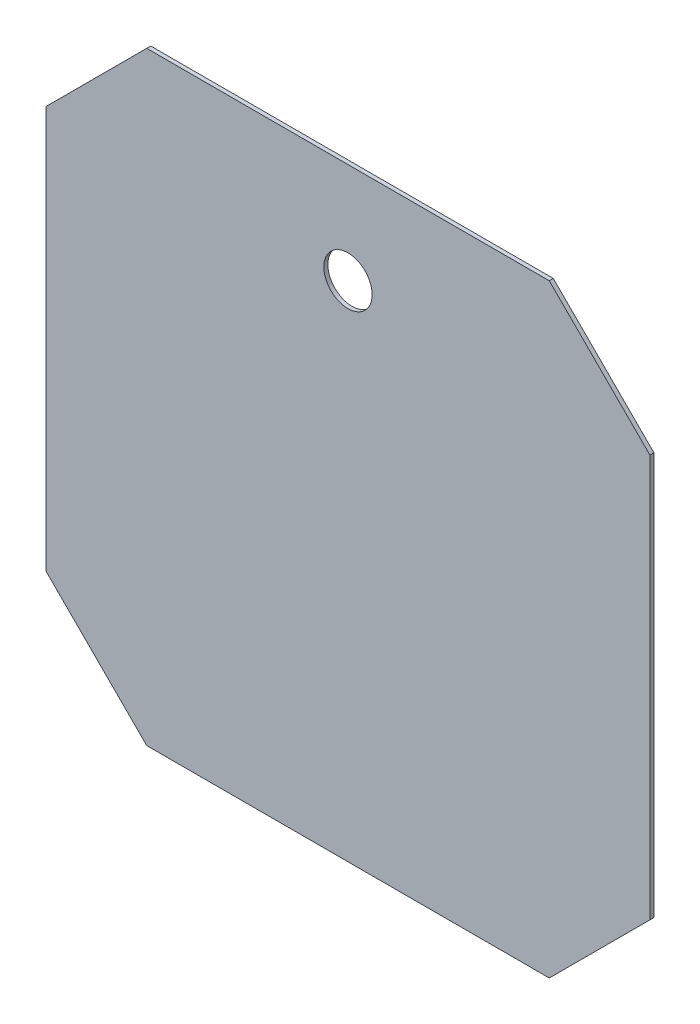
from build123d import *

# Parameters (mm, degrees)
SKETCH1_R           = 6
BOSS_EXTRUDE1_DEPTH = 1


with BuildPart() as part:
    # Sketch1 → Boss-Extrude1 (new body)
    with BuildSketch(Plane.XY):
        Polygon((-75, 50), (-50, 75), (50, 75), (75, 50), (75, -50), (50, -75), (-50, -75), (-75, -50), align=None)
        with Locations((0, 50)):
            Circle(SKETCH1_R, mode=Mode.SUBTRACT)
    extrude(amount=BOSS_EXTRUDE1_DEPTH)


solid = part.part
